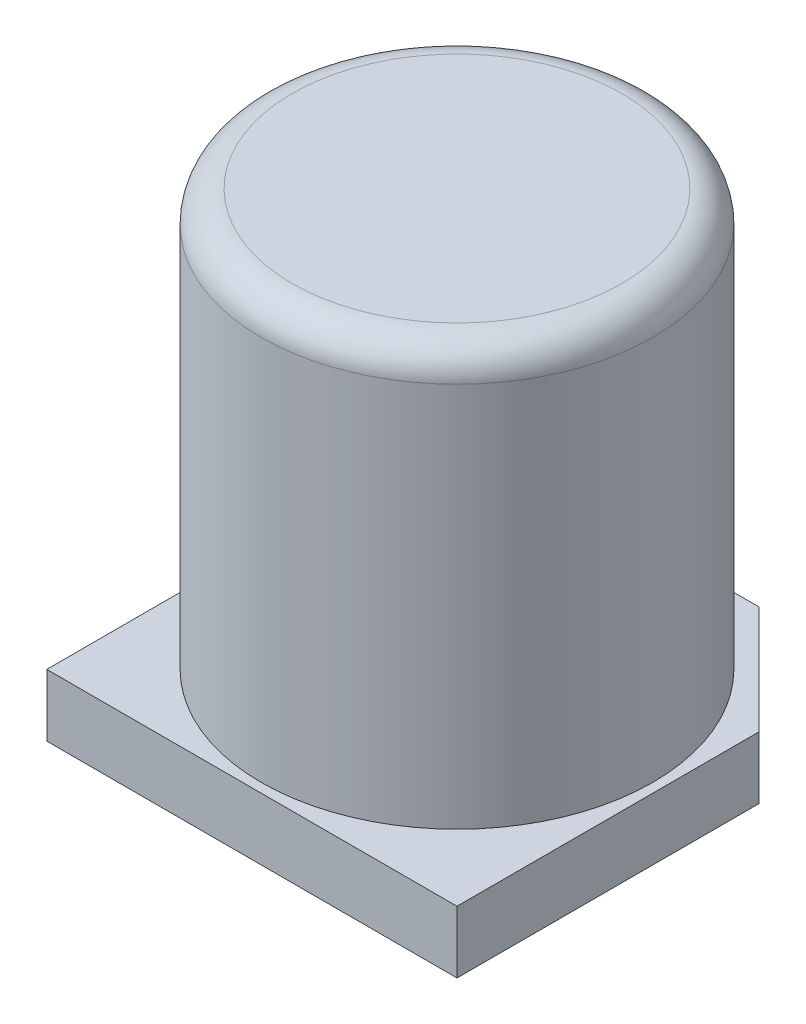
from build123d import *

# Parameters (mm, degrees)
BOSS_EXTRUDE1_DEPTH = 1
SKETCH2_R           = 3.15
BOSS_EXTRUDE2_DEPTH = 6.7
FILLET1_R           = 0.5


with BuildPart() as part:
    # Sketch1 → Boss-Extrude1 (new body)
    with BuildSketch(Plane(origin=(0, 0, 0), x_dir=(1, 0, 0), z_dir=(0, 1, 0))):
        Polygon((-1.562548269, 3.3), (-3.3, 1.562548269), (-3.3, -3.3), (3.3, -3.3), (3.3, 1.562548269), (1.562548269, 3.3), align=None)
    extrude(amount=BOSS_EXTRUDE1_DEPTH)

    # Sketch2 → Boss-Extrude2 (add)
    with BuildSketch(Plane(origin=(0, 1, 0), x_dir=(-1, 0, 0), z_dir=(0, 1, 0))):
        Circle(SKETCH2_R)
    extrude(amount=BOSS_EXTRUDE2_DEPTH)

    # Fillet1
    fillet1_edges = [part.edges().sort_by_distance(p)[0] for p in [
        (3.15, 7.7, 0),
    ]]
    fillet(fillet1_edges, radius=FILLET1_R)


solid = part.part
